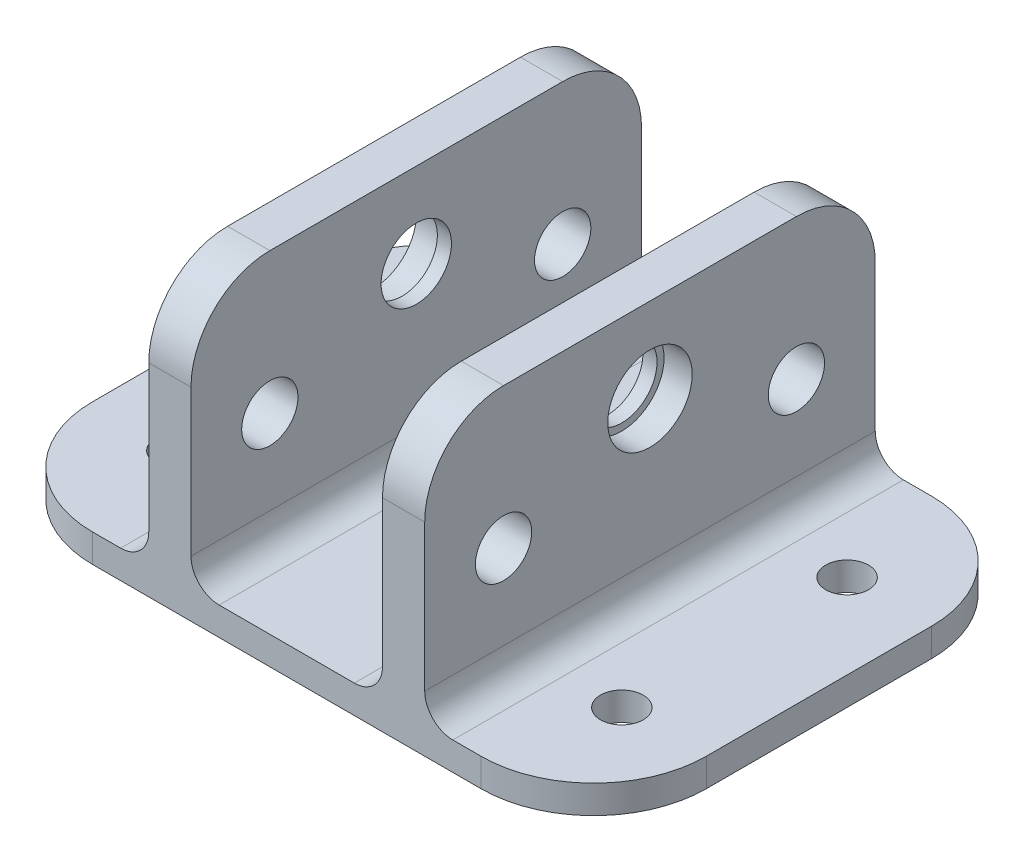
from build123d import *

# Parameters (mm, degrees)
BOSS_EXTRUDE2_DEPTH = 50.8
SKETCH4_R           = 3.175
SKETCH4_R_2         = 3.96875
CUT_EXTRUDE1_DEPTH  = 79.13596947
SKETCH5_R           = 2.413
CUT_EXTRUDE2_DEPTH  = 68.785320544
SKETCH4_3_R         = 4.7625
SKETCH4_3_R_2       = 3.96875
CUT_EXTRUDE3_DEPTH  = 3.175
CUT_EXTRUDE4_START  = -3.175
SKETCH6_R           = 4.7625
SKETCH6_R_2         = 3.96875
CUT_EXTRUDE4_DEPTH  = 3.175
FILLET1_R           = 12.7
FILLET2_R           = 3.175
FILLET3_R           = 8.89


with BuildPart() as part:
    # Sketch3 → Boss-Extrude2 (new body)
    with BuildSketch(Plane.XY):
        Polygon((-34.6075, 0), (34.6075, 0), (34.6075, 3.175), (15.5575, 3.175), (15.5575, 31.75), (10.795, 31.75), (10.795, 3.175), (-10.795, 3.175), (-10.795, 31.75), (-15.5575, 31.75), (-15.5575, 3.175), (-34.6075, 3.175), align=None)
    extrude(amount=BOSS_EXTRUDE2_DEPTH)

    # Sketch4 → Cut-Extrude1 (cut, through all)
    with BuildSketch(Plane.ZY.offset(15.5575)):
        with Locations((8.89, 15.875)):
            Circle(SKETCH4_R)
        with Locations((41.91, 15.875)):
            Circle(SKETCH4_R)
        with Locations((25.4, 22.225)):
            Circle(SKETCH4_R_2)
    extrude(amount=-CUT_EXTRUDE1_DEPTH, mode=Mode.SUBTRACT)

    # Sketch5 → Cut-Extrude2 (cut, through all)
    with BuildSketch(Plane(origin=(0, 3.175, 0), x_dir=(1, 0, 0), z_dir=(0, 1, 0))):
        with Locations((-25.0825, -12.7)):
            Circle(SKETCH5_R)
        with Locations((-25.0825, -38.1)):
            Circle(SKETCH5_R)
        with Locations((25.0825, -12.7)):
            Circle(SKETCH5_R)
        with Locations((25.0825, -38.1)):
            Circle(SKETCH5_R)
    extrude(amount=-CUT_EXTRUDE2_DEPTH, mode=Mode.SUBTRACT)

    # Sketch4_3 → Cut-Extrude3 (cut)
    with BuildSketch(Plane.ZY.offset(15.5575)):
        with Locations((25.4, 22.225)):
            Circle(SKETCH4_3_R)
        with Locations((25.4, 22.225)):
            Circle(SKETCH4_3_R_2, mode=Mode.SUBTRACT)
    extrude(amount=-CUT_EXTRUDE3_DEPTH, mode=Mode.SUBTRACT)

    # Sketch6 → Cut-Extrude4 (cut)
    with BuildSketch(Plane(origin=(15.5575, 0, 0), x_dir=(0, 0, -1), z_dir=(1, 0, 0)).offset(CUT_EXTRUDE4_START)):
        with Locations((-25.4, 22.225)):
            Circle(SKETCH6_R)
        with Locations((-25.4, 22.225)):
            Circle(SKETCH6_R_2, mode=Mode.SUBTRACT)
    extrude(amount=CUT_EXTRUDE4_DEPTH, mode=Mode.SUBTRACT)

    # Fillet1
    fillet1_edges = [part.edges().sort_by_distance(p)[0] for p in [
        (34.6075, 1.5875, 0),
        (34.6075, 1.5875, 50.8),
        (-34.6075, 1.5875, 50.8),
        (-34.6075, 1.5875, 0),
    ]]
    fillet(fillet1_edges, radius=FILLET1_R)

    # Fillet2
    fillet2_edges = [part.edges().sort_by_distance(p)[0] for p in [
        (15.5575, 3.175, 25.4),
        (10.795, 3.175, 25.4),
        (-10.795, 3.175, 25.4),
        (-15.5575, 3.175, 25.4),
    ]]
    fillet(fillet2_edges, radius=FILLET2_R)

    # Fillet3
    fillet3_edges = [part.edges().sort_by_distance(p)[0] for p in [
        (-13.17625, 31.75, 50.8),
        (13.17625, 31.75, 50.8),
        (13.17625, 31.75, 0),
        (-13.17625, 31.75, 0),
    ]]
    fillet(fillet3_edges, radius=FILLET3_R)


solid = part.part
